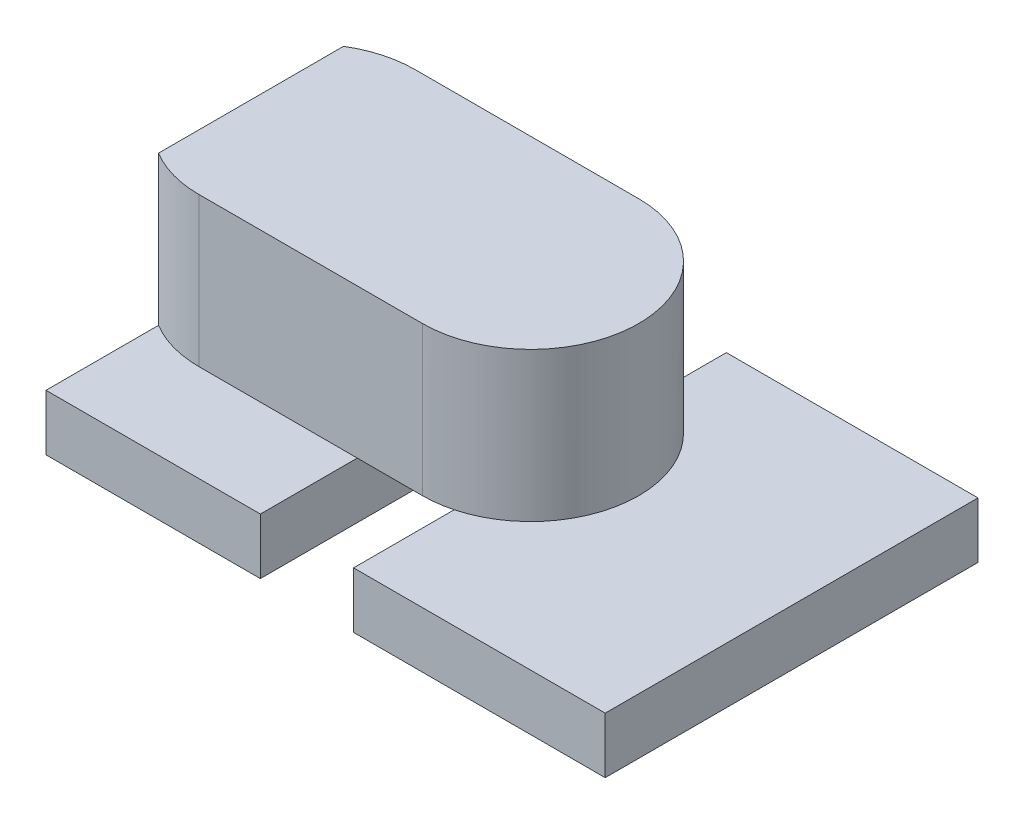
from build123d import *

# Parameters (mm, degrees)
SKETCH1_W           = 15
SKETCH1_H           = 10
BOSS_EXTRUDE1_DEPTH = 1.5
BOSS_EXTRUDE2_DEPTH = 4
SKETCH3_W           = 2.5
SKETCH3_H           = 10
CUT_EXTRUDE1_DEPTH  = 1.5


with BuildPart() as part:
    # Sketch1 → Boss-Extrude1 (new body)
    with BuildSketch(Plane(origin=(0, 0, 0), x_dir=(1, 0, 0), z_dir=(0, 1, 0))):
        Rectangle(SKETCH1_W, SKETCH1_H)
    extrude(amount=BOSS_EXTRUDE1_DEPTH)

    # Sketch2 → Boss-Extrude2 (add)
    with BuildSketch(Plane(origin=(0, 1.5, 0), x_dir=(1, 0, 0), z_dir=(0, 1, 0))):
        with BuildLine():
            Line((-6, 3.4), (0, 3.4))
            ThreePointArc((0, 3.4), (2.9, 0.5), (0, -2.4))
            Line((0, -2.4), (-6, -2.4))
            ThreePointArc((-6, -2.4), (-6.778585026, -2.293529194), (-7.5, -1.981934729))
            Line((-7.5, -1.981934729), (-7.5, 2.981934729))
            ThreePointArc((-7.5, 2.981934729), (-6.778585026, 3.293529194), (-6, 3.4))
        make_face()
    extrude(amount=BOSS_EXTRUDE2_DEPTH)

    # Sketch3 → Cut-Extrude1 (cut)
    with BuildSketch(Plane.XZ):
        with Locations((-0.5, 0)):
            Rectangle(SKETCH3_W, SKETCH3_H)
    extrude(amount=-CUT_EXTRUDE1_DEPTH, mode=Mode.SUBTRACT)


solid = part.part
